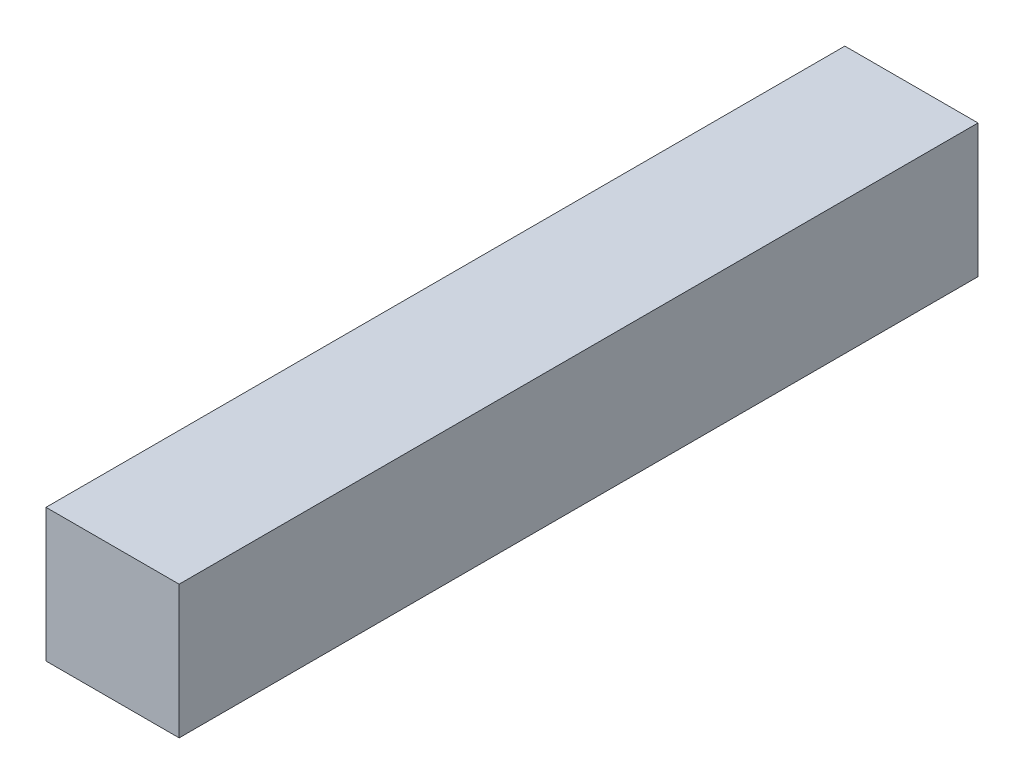
from build123d import *

# Parameters (mm, degrees)
SKETCH3_W                = 3
SKETCH3_H                = 3
BOSS_EXTRUDE1_DEPTH      = 9
BOSS_EXTRUDE1_DEPTH_BACK = 9


with BuildPart() as part:
    # Sketch3 → Boss-Extrude1 (new body, two sides)
    with BuildSketch(Plane.XY) as boss_extrude1_sk:
        Rectangle(SKETCH3_W, SKETCH3_H)
    extrude(amount=BOSS_EXTRUDE1_DEPTH)
    extrude(boss_extrude1_sk.sketch, amount=-BOSS_EXTRUDE1_DEPTH_BACK)


solid = part.part
